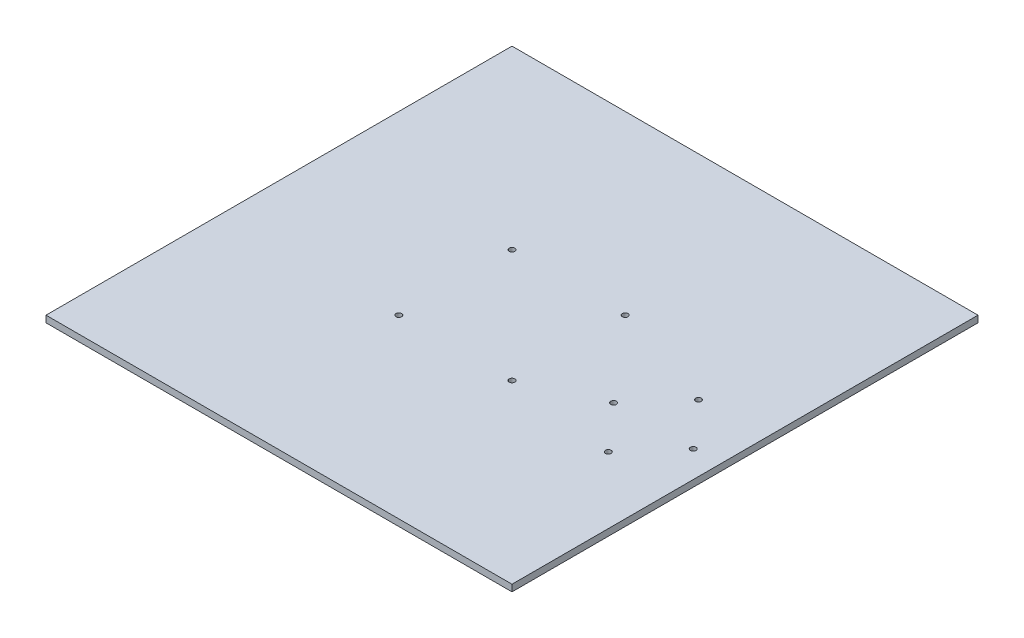
from build123d import *

# Parameters (mm, degrees)
SKETCH1_W             = 222.25
SKETCH1_H             = 222.25
BOSS_EXTRUDE1_DEPTH   = 3.175
F_6_32_TAPPED_HOLE1_D = 2.7051
F_6_32_TAPPED_HOLE3_D = 2.7051


with BuildPart() as part:
    # Sketch1 → Boss-Extrude1 (new body)
    with BuildSketch(Plane(origin=(0, 0, 0), x_dir=(1, 0, 0), z_dir=(0, 1, 0))):
        Rectangle(SKETCH1_W, SKETCH1_H)
    extrude(amount=BOSS_EXTRUDE1_DEPTH)

    # #6-32 Tapped Hole1 (through all)
    with Locations(Plane(origin=(0, 3.175, 0), x_dir=(1, 0, 0), z_dir=(0, 1, 0))):
        with Locations((-26.9875, -26.9875), (-26.9875, 26.9875), (26.9875, 26.9875), (26.9875, -26.9875)):
            Hole(F_6_32_TAPPED_HOLE1_D / 2)

    # #6-32 Tapped Hole3 (through all)
    with Locations(Plane(origin=(0, 3.175, 0), x_dir=(1, 0, 0), z_dir=(0, 1, 0))):
        with Locations((60.425, -12), (79.425, -33.5), (98.425, -12), (79.425, 9.5)):
            Hole(F_6_32_TAPPED_HOLE3_D / 2)


solid = part.part
